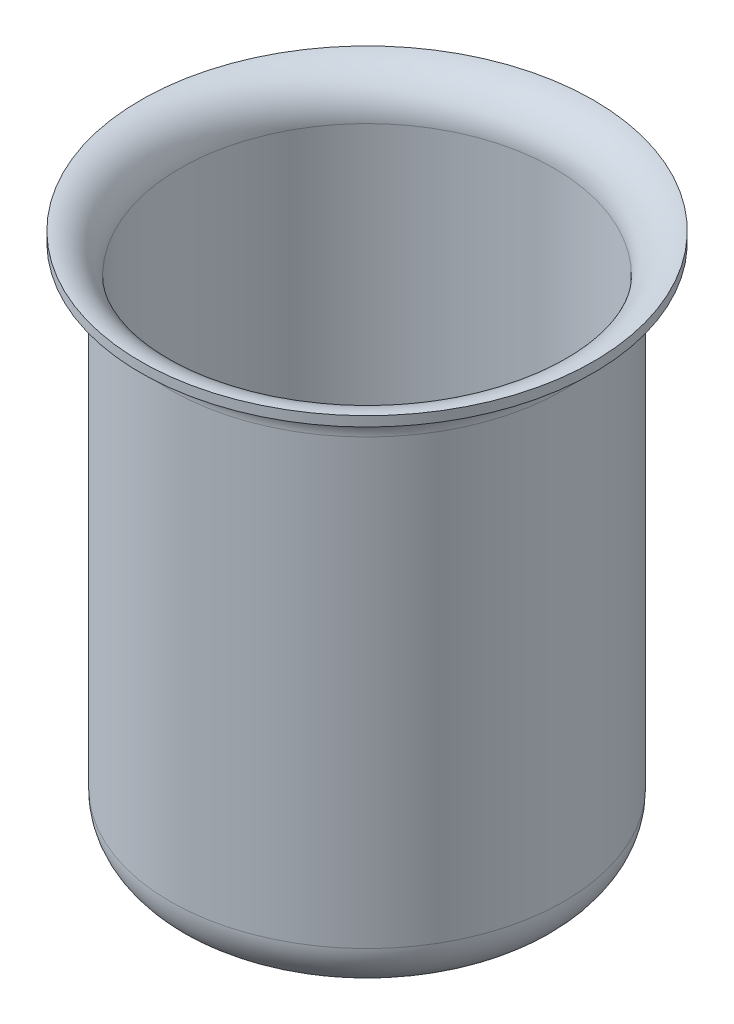
from build123d import *


with BuildPart() as part:
    # Skica1 → Rotace tenkostěnný1 (revolve)
    with BuildSketch(Plane.XY):
        with BuildLine():
            Line((0, 0), (-15, 0))
            ThreePointArc((-15, 0), (-18.535533906, 1.464466094), (-20, 5))
            Line((-20, 5), (-20, 50))
            ThreePointArc((-20, 50), (-20.878679656, 52.121320344), (-23, 53))
            Line((-23, 53), (-23, 54))
            ThreePointArc((-23, 54), (-20.171572875, 52.828427125), (-19, 50))
            Line((-19, 50), (-19, 5))
            ThreePointArc((-19, 5), (-17.828427125, 2.171572875), (-15, 1))
            Line((-15, 1), (0, 1))
            Line((0, 1), (0, 0))
        make_face()
    revolve(axis=Axis((0, 0, 0), (0, 1, 0)))


solid = part.part
